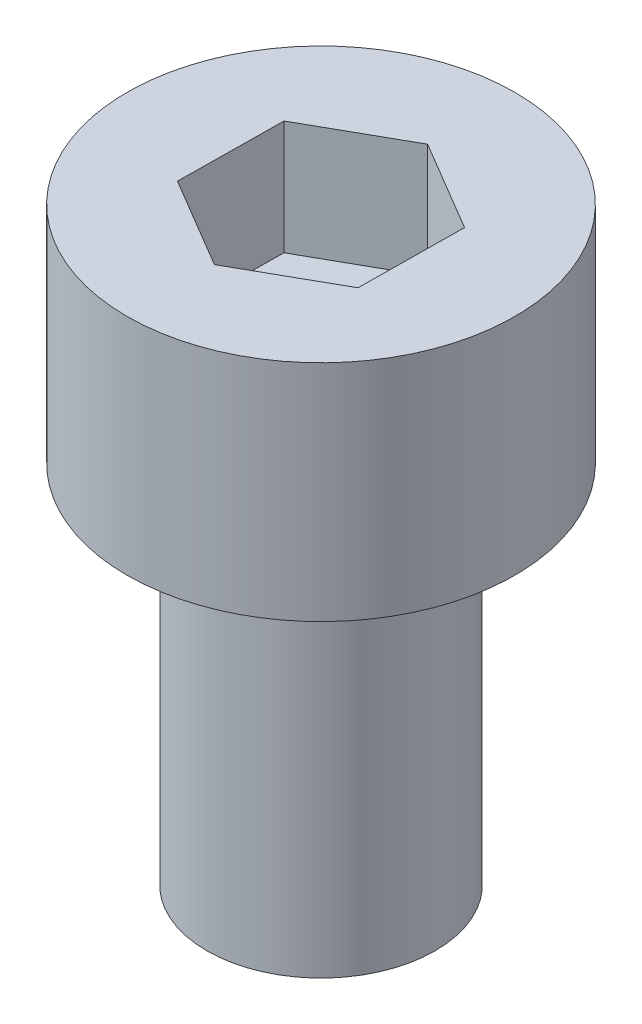
from build123d import *

# Parameters (mm, degrees)
SKETCH_1_R          = 2.5
EXTRUDE_1_DEPTH     = 8
SKETCH_2_R          = 4.25
EXTRUDE_2_DEPTH     = 4.91
CUT_EXTRUDE_1_DEPTH = 2.5


with BuildPart() as part:
    # 草图1 → 凸台-拉伸1 (new body)
    with BuildSketch(Plane(origin=(0, 0, 0), x_dir=(1, 0, 0), z_dir=(0, 1, 0))):
        Circle(SKETCH_1_R)
    extrude(amount=EXTRUDE_1_DEPTH)

    # 草图2 → 凸台-拉伸2 (add)
    with BuildSketch(Plane(origin=(0, 8, 0), x_dir=(1, 0, 0), z_dir=(0, 1, 0))):
        Circle(SKETCH_2_R)
    extrude(amount=EXTRUDE_2_DEPTH)

    # 草图3 → 切除-拉伸1 (cut)
    with BuildSketch(Plane(origin=(0, 12.91, 0), x_dir=(1, 0, 0), z_dir=(0, 1, 0))):
        Polygon((1.987239819, -1.176525067), (2.012520506, 1.132737633), (0.025280687, 2.309262701), (-1.987239819, 1.176525067), (-2.012520506, -1.132737633), (-0.025280687, -2.309262701), align=None)
    extrude(amount=-CUT_EXTRUDE_1_DEPTH, mode=Mode.SUBTRACT)


solid = part.part
